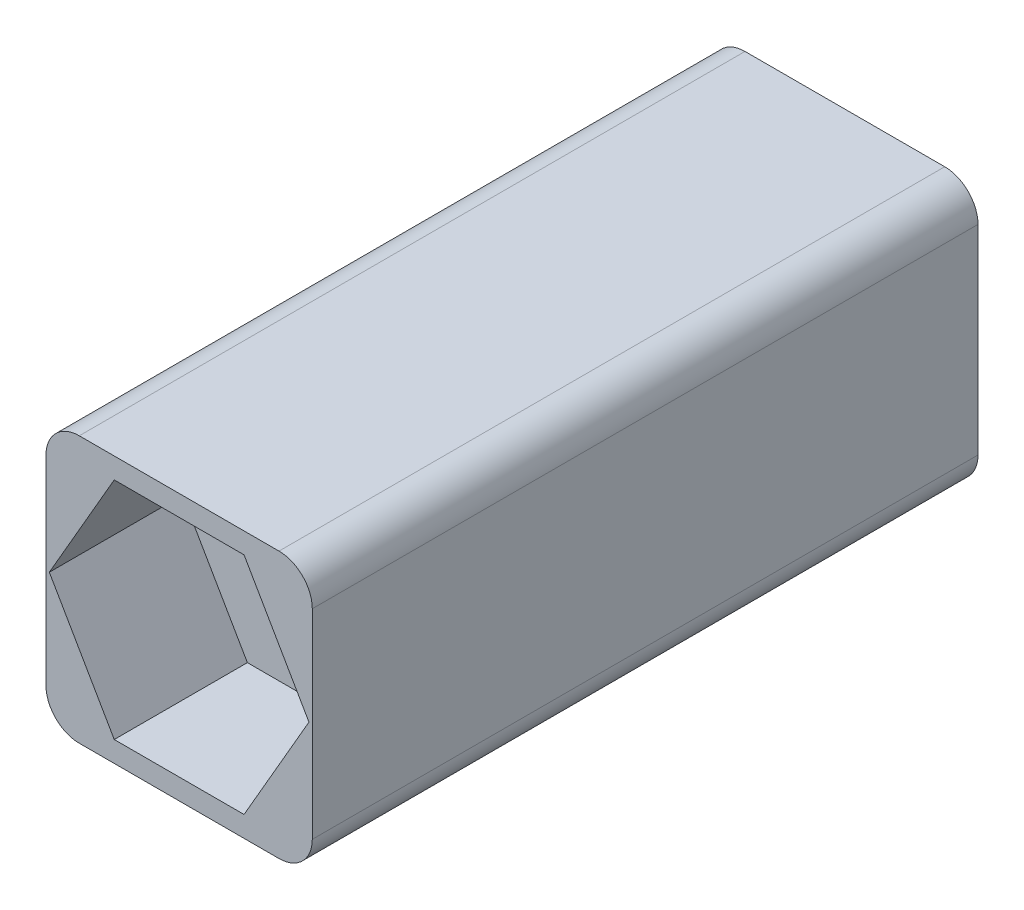
from build123d import *

# Parameters (mm, degrees)
SKETCH1_W           = 8
SKETCH1_H           = 8
BOSS_EXTRUDE1_DEPTH = 20
CUT_EXTRUDE1_DEPTH  = 20
CUT_EXTRUDE8_DEPTH  = 4
FILLET1_R           = 1
FILLET2_R           = 1


with BuildPart() as part:
    # Sketch1 → Boss-Extrude1 (new body)
    with BuildSketch(Plane.XY):
        with Locations((1.399149149, 0.658917954)):
            Rectangle(SKETCH1_W, SKETCH1_H)
    extrude(amount=BOSS_EXTRUDE1_DEPTH)

    # Sketch4 → Cut-Extrude1 (cut)
    with BuildSketch(Plane.XY.offset(20)):
        with BuildLine():
            ThreePointArc((3.399149149, 0.658917954), (2.164516014, 2.506677019), (-0.015064413, 2.073131517))
            Line((-0.015064413, 2.073131517), (2.813362712, -0.755295608))
            ThreePointArc((2.813362712, -0.755295608), (3.246908214, -0.10644891), (3.399149149, 0.658917954))
        make_face()
        with BuildLine():
            Line((2.813362712, -0.755295608), (-0.015064413, 2.073131517))
            ThreePointArc((-0.015064413, 2.073131517), (-0.015064413, -0.755295608), (2.813362712, -0.755295608))
        make_face()
    extrude(amount=-CUT_EXTRUDE1_DEPTH, mode=Mode.SUBTRACT)

    # Sketch5 → Cut-Extrude8 (cut)
    with BuildSketch(Plane.XY.offset(20)):
        Polygon((-2.500850851, 0.658917954), (-0.550850851, -2.71858112), (3.349149149, -2.71858112), (5.299149149, 0.658917954), (3.349149149, 4.036417029), (-0.550850851, 4.036417029), align=None)
    extrude(amount=-CUT_EXTRUDE8_DEPTH, mode=Mode.SUBTRACT)

    # Fillet1
    fillet1_edges = [part.edges().sort_by_distance(p)[0] for p in [
        (-2.600850851, 4.658917954, 10),
        (5.399149149, 4.658917954, 10),
        (5.399149149, -3.341082046, 10),
    ]]
    fillet(fillet1_edges, radius=FILLET1_R)

    # Fillet2
    fillet2_edges = [part.edges().sort_by_distance(p)[0] for p in [
        (-2.600850851, -3.341082046, 10),
    ]]
    fillet(fillet2_edges, radius=FILLET2_R)


solid = part.part
